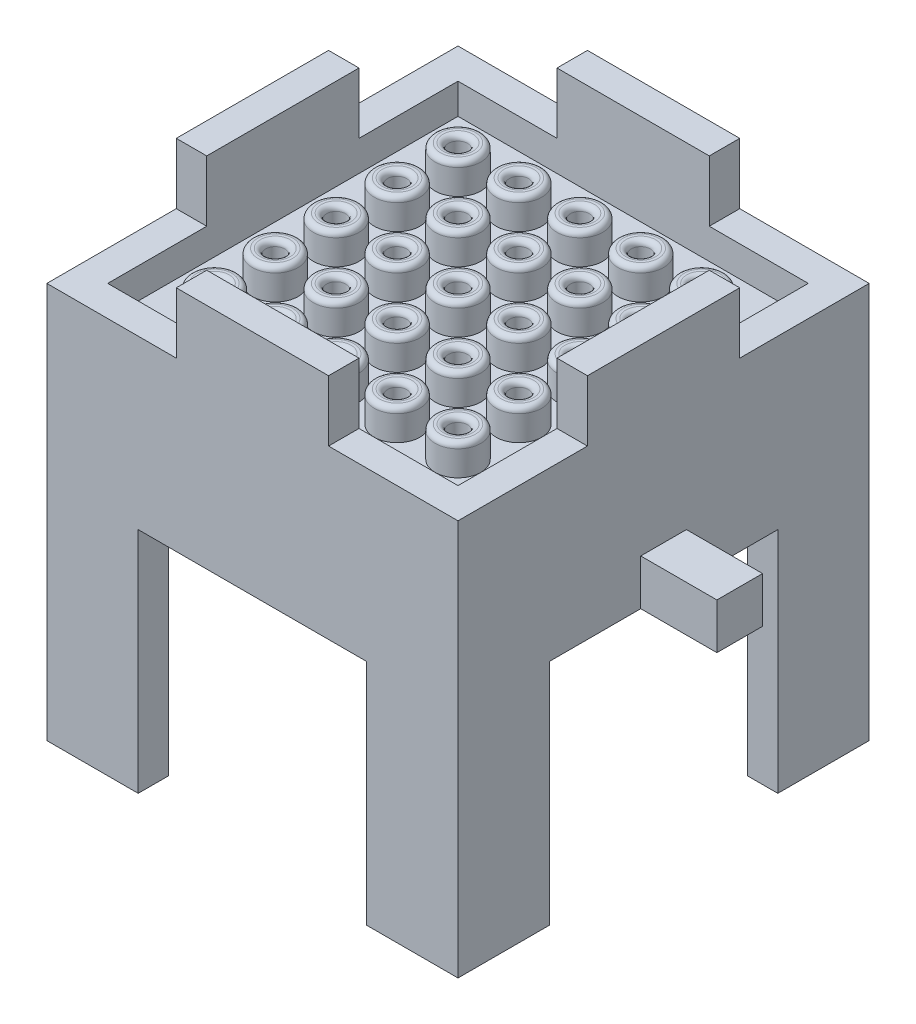
from build123d import *

# Parameters (mm, degrees)
SKETCH1_W              = 27
SKETCH1_H              = 27
SKETCH1_W_2            = 23
SKETCH1_H_2            = 23
BOSS_EXTRUDE1_DEPTH    = 2
SKETCH2_W              = 27
SKETCH2_H              = 27
BOSS_EXTRUDE2_DEPTH    = 2
SKETCH3_W              = 27
SKETCH3_H              = 27
SKETCH3_W_2            = 23
SKETCH3_H_2            = 23
BOSS_EXTRUDE3_DEPTH    = 5
SKETCH6_R              = 1.5
BOSS_EXTRUDE5_DEPTH    = 2
SKETCH7_R              = 0.625
CUT_EXTRUDE2_DEPTH     = 4
FILLET3_R              = 0.35
LPATTERN1_COUNT        = 5
LPATTERN1_PITCH        = 4
LPATTERN1_COUNT_DIR2   = 5
LPATTERN1_PITCH_DIR2   = 4
FILLET3_OF_LPATTERN1_R = 0.35
SKETCH11_R             = 0.75
BOSS_EXTRUDE8_DEPTH    = 5
LPATTERN2_COUNT        = 6
LPATTERN2_PITCH        = 4
LPATTERN2_COUNT_DIR2   = 6
LPATTERN2_PITCH_DIR2   = 4
SKETCH8_W              = 27
SKETCH8_H              = 27
BOSS_EXTRUDE6_DEPTH    = 2
SKETCH9_R              = 4.25
CUT_EXTRUDE3_DEPTH     = 7
SKETCH10_W             = 2
SKETCH10_H             = 10
BOSS_EXTRUDE7_DEPTH    = 4
CIRPATTERN1_COUNT      = 4
SKETCH12_W             = 3
SKETCH12_H             = 3
BOSS_EXTRUDE9_DEPTH    = 5
CIRPATTERN2_COUNT      = 2
BOSS_EXTRUDE10_DEPTH   = 15
CIRPATTERN3_COUNT      = 4


with BuildPart() as part:
    # Sketch1 → Boss-Extrude1 (new body)
    with BuildSketch(Plane(origin=(0, 0, 0), x_dir=(1, 0, 0), z_dir=(0, 1, 0))):
        Rectangle(SKETCH1_W, SKETCH1_H)
        Rectangle(SKETCH1_W_2, SKETCH1_H_2, mode=Mode.SUBTRACT)
    extrude(amount=BOSS_EXTRUDE1_DEPTH)

    # Sketch2 → Boss-Extrude2 (add)
    with BuildSketch(Plane.XZ):
        Rectangle(SKETCH2_W, SKETCH2_H)
    extrude(amount=BOSS_EXTRUDE2_DEPTH)

    # Sketch3 → Boss-Extrude3 (add)
    with BuildSketch(Plane.XZ.offset(2)):
        Rectangle(SKETCH3_W, SKETCH3_H)
        Rectangle(SKETCH3_W_2, SKETCH3_H_2, mode=Mode.SUBTRACT)
    extrude(amount=BOSS_EXTRUDE3_DEPTH)

    # Sketch6 → Boss-Extrude5 (add)
    with BuildSketch(Plane(origin=(0, 0, 0), x_dir=(1, 0, 0), z_dir=(0, 1, 0))):
        with Locations((8, 8)):
            Circle(SKETCH6_R)
    boss_extrude5 = extrude(amount=BOSS_EXTRUDE5_DEPTH)

    # Sketch7 → Cut-Extrude2 (cut)
    with BuildSketch(Plane(origin=(0, 2, 0), x_dir=(1, 0, 0), z_dir=(0, 1, 0))):
        with Locations((8, 8)):
            Circle(SKETCH7_R)
    cut_extrude2 = extrude(amount=-CUT_EXTRUDE2_DEPTH, mode=Mode.SUBTRACT)

    # Fillet3
    fillet3_edges = [part.edges().sort_by_distance(p)[0] for p in [
        (6.5, 2, -8),
        (7.375, 2, -8),
    ]]
    fillet(fillet3_edges, radius=FILLET3_R)

    # LPattern1: Boss-Extrude5, Cut-Extrude2 5 × 5
    with Locations(*[(-j * LPATTERN1_PITCH_DIR2, 0, i * LPATTERN1_PITCH) for i in range(LPATTERN1_COUNT) for j in range(LPATTERN1_COUNT_DIR2) if (i, j) != (0, 0)]):
        add(boss_extrude5)
        add(cut_extrude2, mode=Mode.SUBTRACT)

    # Fillet3 of LPattern1
    fillet3_of_lpattern1_edges = [part.edges().sort_by_distance(p)[0] for p in [
        (2.5, 2, -8),
        (3.375, 2, -8),
        (-1.5, 2, -8),
        (-0.625, 2, -8),
        (-5.5, 2, -8),
        (-4.625, 2, -8),
        (-9.5, 2, -8),
        (-8.625, 2, -8),
        (6.5, 2, -4),
        (7.375, 2, -4),
        (2.5, 2, -4),
        (3.375, 2, -4),
        (-1.5, 2, -4),
        (-0.625, 2, -4),
        (-5.5, 2, -4),
        (-4.625, 2, -4),
        (-9.5, 2, -4),
        (-8.625, 2, -4),
        (6.5, 2, 0),
        (7.375, 2, 0),
        (2.5, 2, 0),
        (3.375, 2, 0),
        (-1.5, 2, 0),
        (-0.625, 2, 0),
        (-5.5, 2, 0),
        (-4.625, 2, 0),
        (-9.5, 2, 0),
        (-8.625, 2, 0),
        (6.5, 2, 4),
        (7.375, 2, 4),
        (2.5, 2, 4),
        (3.375, 2, 4),
        (-1.5, 2, 4),
        (-0.625, 2, 4),
        (-5.5, 2, 4),
        (-4.625, 2, 4),
        (-9.5, 2, 4),
        (-8.625, 2, 4),
        (6.5, 2, 8),
        (7.375, 2, 8),
        (2.5, 2, 8),
        (3.375, 2, 8),
        (-1.5, 2, 8),
        (-0.625, 2, 8),
        (-5.5, 2, 8),
        (-4.625, 2, 8),
        (-9.5, 2, 8),
        (-8.625, 2, 8),
    ]]
    fillet(fillet3_of_lpattern1_edges, radius=FILLET3_OF_LPATTERN1_R)

    # Sketch11 → Boss-Extrude8 (add)
    with BuildSketch(Plane.XZ.offset(2)):
        with Locations((-9.9, 9.9)):
            Circle(SKETCH11_R)
    boss_extrude8 = extrude(amount=BOSS_EXTRUDE8_DEPTH)

    # LPattern2: Boss-Extrude8 6 × 6
    with Locations(*[(i * LPATTERN2_PITCH, 0, -j * LPATTERN2_PITCH_DIR2) for i in range(LPATTERN2_COUNT) for j in range(LPATTERN2_COUNT_DIR2) if (i, j) != (0, 0)]):
        add(boss_extrude8)

    # Sketch8 → Boss-Extrude6 (add)
    with BuildSketch(Plane.XZ.offset(7)):
        Rectangle(SKETCH8_W, SKETCH8_H)
    extrude(amount=BOSS_EXTRUDE6_DEPTH)

    # Sketch9 → Cut-Extrude3 (cut)
    with BuildSketch(Plane.XZ.offset(9)):
        Circle(SKETCH9_R)
    extrude(amount=-CUT_EXTRUDE3_DEPTH, mode=Mode.SUBTRACT)

    # Sketch10 → Boss-Extrude7 (add)
    with BuildSketch(Plane(origin=(0, 2, 0), x_dir=(1, 0, 0), z_dir=(0, 1, 0))):
        with Locations((-12.5, 0)):
            Rectangle(SKETCH10_W, SKETCH10_H)
    boss_extrude7 = extrude(amount=BOSS_EXTRUDE7_DEPTH)

    # CirPattern1: Boss-Extrude7 ×4 about axis
    cirpattern1_axis = Axis((0, 0, 0), (0, 1, 0))
    for i in range(1, CIRPATTERN1_COUNT):
        add(boss_extrude7.rotate(cirpattern1_axis, i * 360 / CIRPATTERN1_COUNT))

    # Sketch12 → Boss-Extrude9 (add)
    with BuildSketch(Plane.ZY.offset(13.5)):
        with Locations((0, -7.5)):
            Rectangle(SKETCH12_W, SKETCH12_H)
    boss_extrude9 = extrude(amount=BOSS_EXTRUDE9_DEPTH)

    # CirPattern2: Boss-Extrude9 ×2 about axis
    cirpattern2_axis = Axis((0, 0, 0), (0, 1, 0))
    for i in range(1, CIRPATTERN2_COUNT):
        add(boss_extrude9.rotate(cirpattern2_axis, i * 360 / CIRPATTERN2_COUNT))

    # Sketch13 → Boss-Extrude10 (add)
    with BuildSketch(Plane.XZ.offset(9)):
        Polygon((-13.5, 7.5), (-11.5, 7.5), (-11.5, 11.5), (-7.5, 11.5), (-7.5, 13.5), (-13.5, 13.5), (-13.5, 11.625363163), align=None)
    boss_extrude10 = extrude(amount=BOSS_EXTRUDE10_DEPTH)

    # CirPattern3: Boss-Extrude10 ×4 about axis
    cirpattern3_axis = Axis((0, 0, 0), (0, 1, 0))
    for i in range(1, CIRPATTERN3_COUNT):
        add(boss_extrude10.rotate(cirpattern3_axis, i * 360 / CIRPATTERN3_COUNT))


solid = part.part
